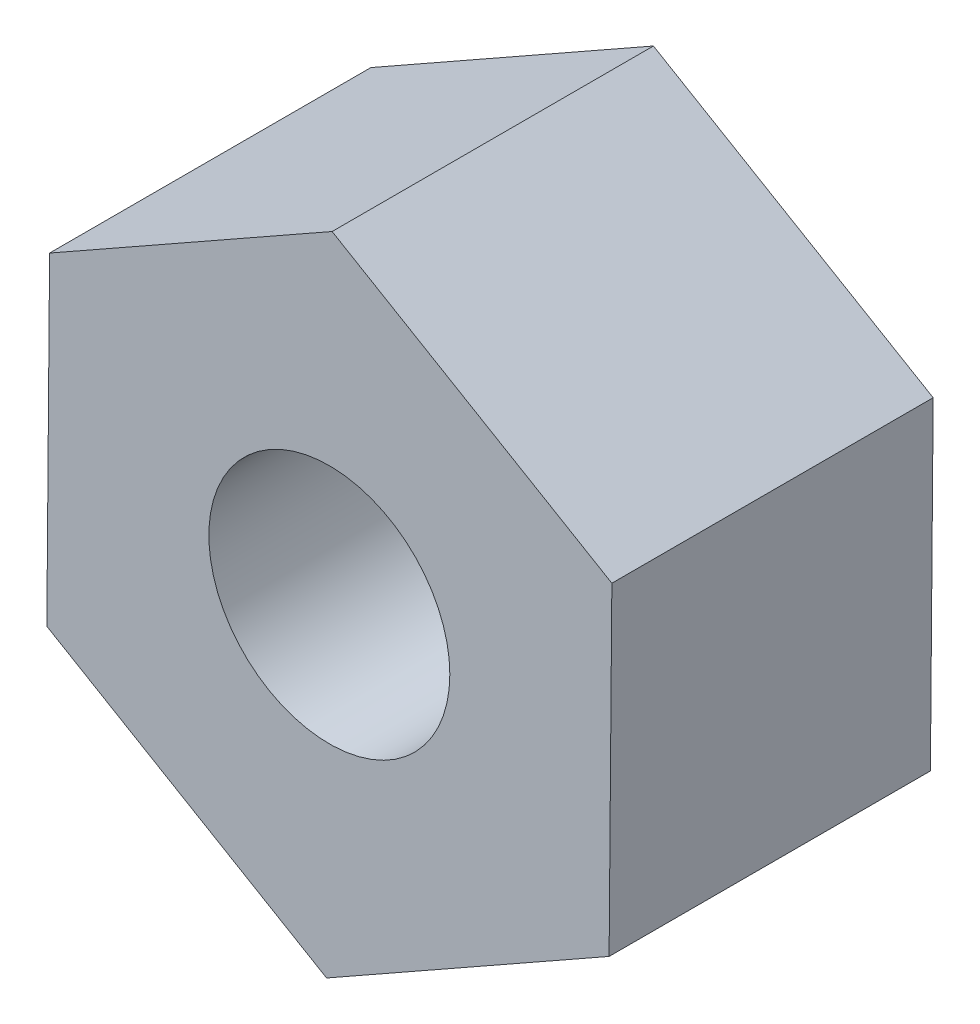
from build123d import *

# Parameters (mm, degrees)
SKETCH1_R           = 1.5
BOSS_EXTRUDE2_DEPTH = 4


with BuildPart() as part:
    # Sketch1 → Boss-Extrude2 (new body)
    with BuildSketch(Plane.XY):
        Polygon((-3.48265519, 2.050474619), (-3.517090705, -1.990830557), (-0.034435515, -4.041305176), (3.48265519, -2.050474619), (3.517090705, 1.990830557), (0.034435515, 4.041305176), align=None)
        Circle(SKETCH1_R, mode=Mode.SUBTRACT)
    extrude(amount=BOSS_EXTRUDE2_DEPTH)


solid = part.part
